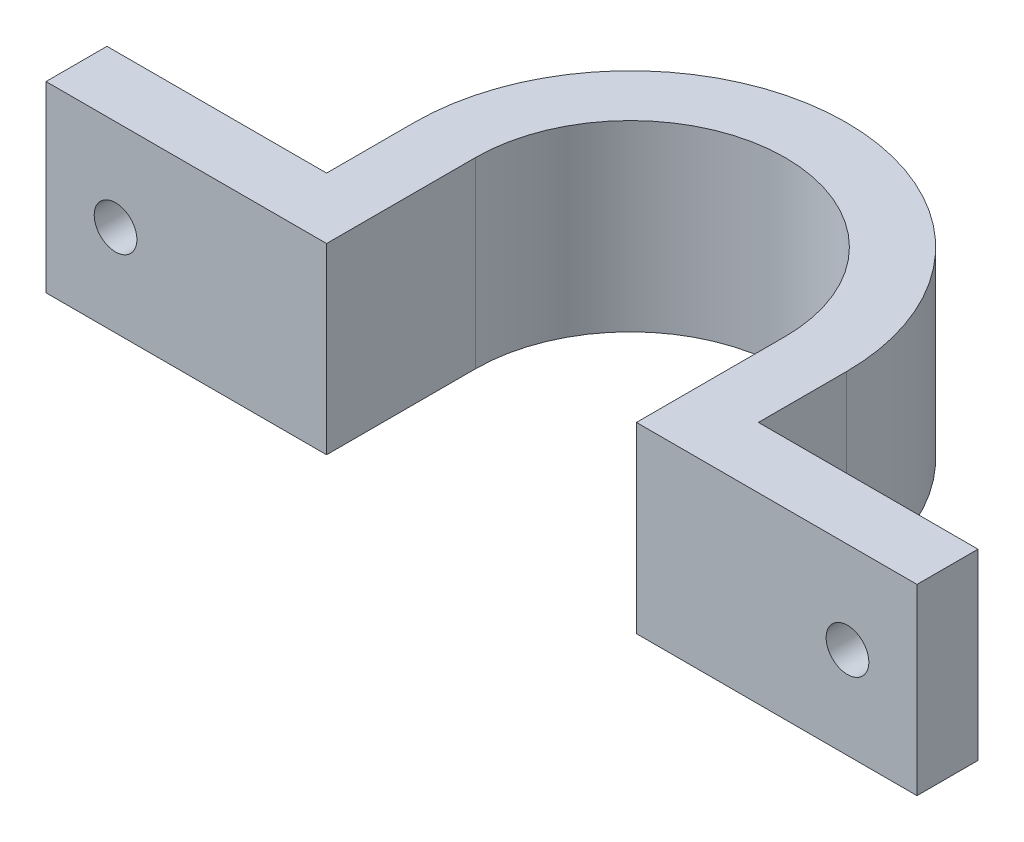
from build123d import *

# Parameters (mm, degrees)
BOSS_EXTRUDE1_DEPTH = 15
SKETCH2_R           = 1.75
CUT_EXTRUDE1_DEPTH  = 6


with BuildPart() as part:
    # Sketch1 → Boss-Extrude1 (new body)
    with BuildSketch(Plane(origin=(0, 0, 0), x_dir=(1, 0, 0), z_dir=(0, 1, 0))):
        with BuildLine():
            Line((-35.7, -7.2), (-35.7, -12.2))
            Line((-35.7, -12.2), (-12.7, -12.2))
            Line((-12.7, -12.2), (-12.7, 0))
            ThreePointArc((-12.7, 0), (0, 12.7), (12.7, 0))
            Line((12.7, 0), (12.7, -12.2))
            Line((12.7, -12.2), (35.7, -12.2))
            Line((35.7, -12.2), (35.7, -7.2))
            Line((35.7, -7.2), (17.7, -7.2))
            Line((17.7, -7.2), (17.7, 0))
            ThreePointArc((17.7, 0), (0, 17.7), (-17.7, 0))
            Line((-17.7, 0), (-17.7, -7.2))
            Line((-17.7, -7.2), (-35.7, -7.2))
        make_face()
    extrude(amount=BOSS_EXTRUDE1_DEPTH)

    # Sketch2 → Cut-Extrude1 (cut, through all)
    with BuildSketch(Plane(origin=(0, 0, 7.2), x_dir=(-1, 0, 0), z_dir=(0, 0, -1))):
        with Locations((-30, 7.5)):
            Circle(SKETCH2_R)
        with Locations((30, 7.5)):
            Circle(SKETCH2_R)
    extrude(amount=-CUT_EXTRUDE1_DEPTH, mode=Mode.SUBTRACT)


solid = part.part
